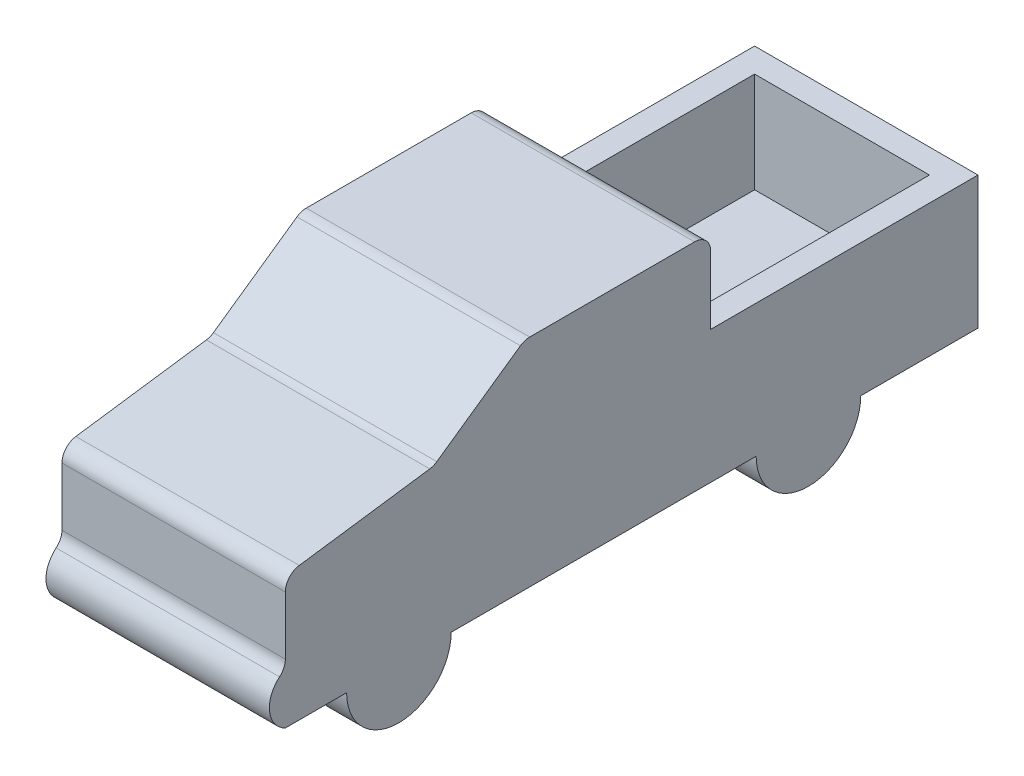
from build123d import *

# Parameters (mm, degrees)
BOSS_EXTRUDE1_DEPTH = 69
SKETCH4_W           = 15
SKETCH4_H           = 150.1
BOSS_EXTRUDE2_DEPTH = 61.9
BOSS_EXTRUDE3_DEPTH = 20.4
FILLET1_R           = 10


with BuildPart() as part:
    # Sketch2 → Boss-Extrude1 (new body, symmetric)
    with BuildSketch(Plane(origin=(0, 0, 0), x_dir=(0, 0, -1), z_dir=(1, 0, 0))):
        with BuildLine():
            Line((-262.793626597, 0), (0, 0))
            Line((0, 0), (165.1, 0))
            Line((165.1, 0), (165.1, 81.9))
            Line((165.1, 81.9), (150.1, 81.9))
            Line((150.1, 81.9), (150.1, 20))
            Line((150.1, 20), (0, 20))
            Line((0, 20), (0, 133.7))
            Line((0, 133.7), (-115, 133.7))
            Line((-115, 133.7), (-171.193830238, 94.352656466))
            Line((-171.193830238, 94.352656466), (-262.793626597, 81.479144628))
            Line((-262.793626597, 81.479144628), (-262.793626597, 31.479144628))
            ThreePointArc((-262.793626597, 31.479144628), (-272.644060375, 15.739572314), (-262.793626597, 0))
        make_face()
    extrude(amount=BOSS_EXTRUDE1_DEPTH, both=True)

    # Sketch4 → Boss-Extrude2 (add)
    with BuildSketch(Plane(origin=(0, 20, 0), x_dir=(1, 0, 0), z_dir=(0, 1, 0))):
        with Locations((61.5, 75.05)):
            Rectangle(SKETCH4_W, SKETCH4_H)
    boss_extrude2 = extrude(amount=BOSS_EXTRUDE2_DEPTH)

    # Mirror1: Boss-Extrude2 across plane
    add(boss_extrude2.mirror(Plane(origin=(0, 0, 0), x_dir=(0, 0, 1), z_dir=(1, 0, 0))))

    # Sketch5 → Boss-Extrude3 (add)
    with BuildSketch(Plane(origin=(69, 0, 0), x_dir=(0, 0, -1), z_dir=(1, 0, 0))):
        with BuildLine():
            Line((-224.944060375, 0), (-160.344060375, 0))
            ThreePointArc((-160.344060375, 0), (-192.644060375, -32.3), (-224.944060375, 0))
        make_face()
        with BuildLine():
            Line((28.055939625, 0), (92.655939625, 0))
            ThreePointArc((92.655939625, 0), (60.355939625, -32.3), (28.055939625, 0))
        make_face()
    boss_extrude3 = extrude(amount=-BOSS_EXTRUDE3_DEPTH)

    # Mirror2: Boss-Extrude3 across plane
    add(boss_extrude3.mirror(Plane(origin=(0, 0, 0), x_dir=(0, 0, 1), z_dir=(1, 0, 0))))

    # Fillet1
    fillet1_edges = [part.edges().sort_by_distance(p)[0] for p in [
        (0, 31.479144628, 262.793626597),
        (0, 81.479144628, 262.793626597),
        (0, 94.352656466, 171.193830238),
        (0, 133.7, 115),
        (0, 133.7, 0),
    ]]
    fillet(fillet1_edges, radius=FILLET1_R)


solid = part.part
